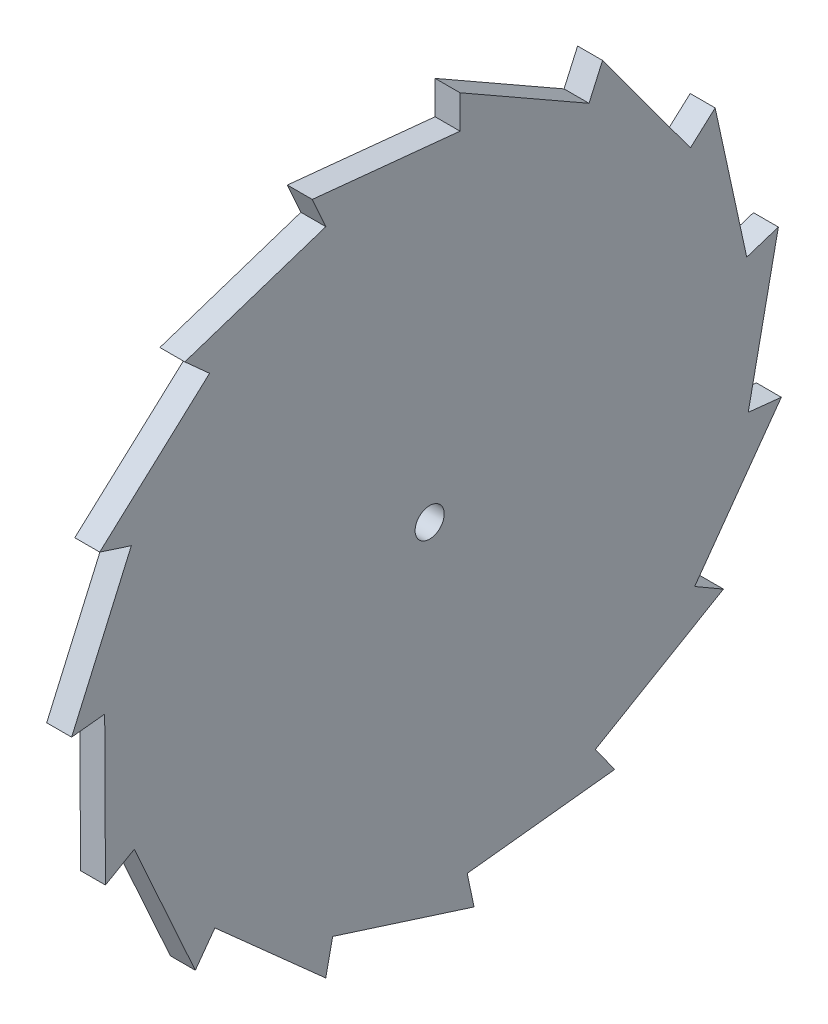
from build123d import *

# Parameters (mm, degrees)
BOSS_EXTRUDE1_DEPTH         = 6
TAP_DRILL_FOR_M8X1_0_TAP2_D = 7


with BuildPart() as part:
    # Sketch1 → Boss-Extrude1 (new body)
    with BuildSketch(Plane(origin=(0, 0, 0), x_dir=(0, 0, -1), z_dir=(1, 0, 0))):
        Polygon((-28.922954929, 86.159638097), (-28.922954929, 94.159638097), (2.104632598, 76.455689895), (5.358525743, 83.764053556), (26.502792929, 54.9706353), (32.447951533, 60.323680151), (40.052862492, 25.419435438), (47.661314622, 27.891571393), (40.411911161, -7.088238772), (48.368086324, -7.924466478), (27.517856159, -36.931515135), (34.44605939, -40.931515135), (3.600196736, -58.95022005), (8.302478754, -65.422356005), (-27.20548651, -69.337119405), (-25.542192984, -77.162300211), (-59.572611085, -66.296223938), (-61.235904612, -74.121404744), (-87.904607103, -50.353332102), (-92.606889121, -56.825468057), (-107.302615065, -24.265114732), (-114.230818295, -28.265114732), (-114.412543169, 7.457538386), (-122.368718332, 6.62131068), (-108.005020253, 39.329492336), (-115.613472384, 41.801628291), (-89.187965242, 65.839796731), (-95.133123845, 71.192841582), (-61.215017893, 82.404579105), (-64.468911037, 89.712942766), align=None)
    extrude(amount=BOSS_EXTRUDE1_DEPTH)

    # Tap Drill for M8x1.0 Tap2 (through all)
    with Locations(Plane.ZY):
        with Locations((36.235904612, 8.321002744)):
            Hole(TAP_DRILL_FOR_M8X1_0_TAP2_D / 2)


solid = part.part
